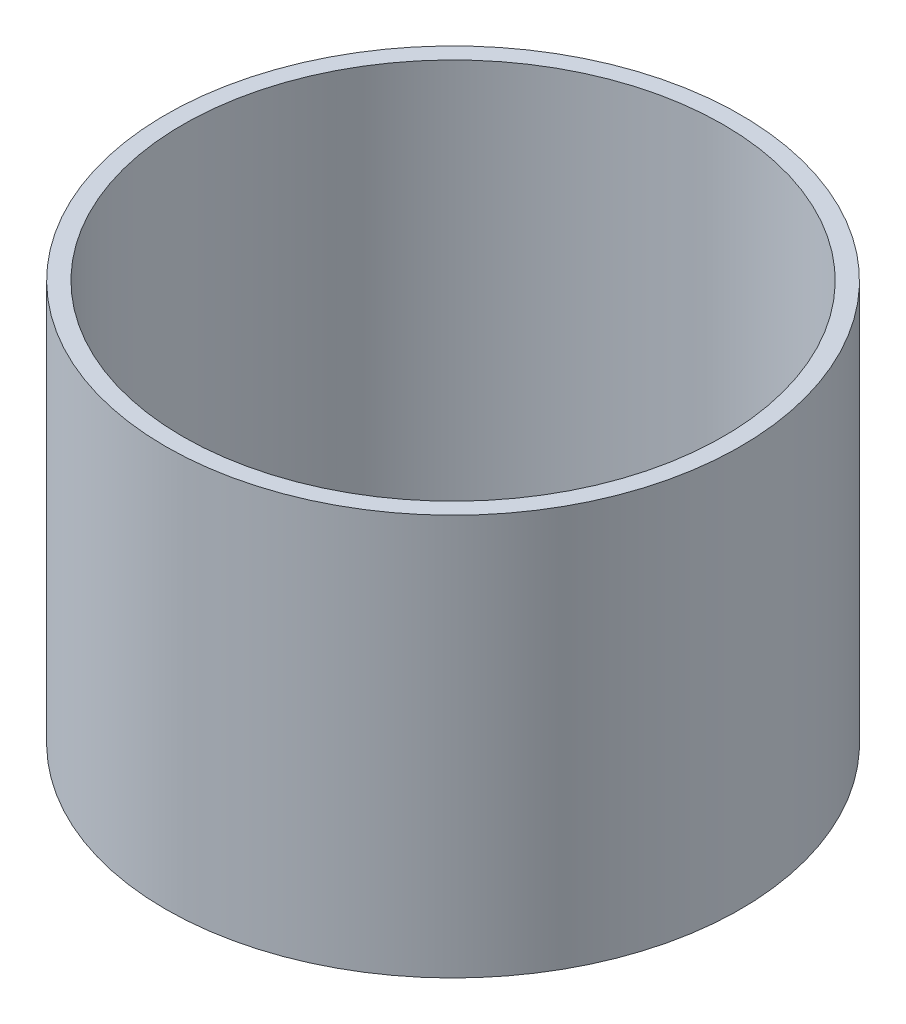
from build123d import *

# Parameters (mm, degrees)
ESQUISSE1_R        = 50.2
ESQUISSE1_R_2      = 47.2
BOSS_EXTRU_1_DEPTH = 70


with BuildPart() as part:
    # Esquisse1 → Boss.-Extru.1 (new body)
    with BuildSketch(Plane(origin=(0, 0, 0), x_dir=(1, 0, 0), z_dir=(0, 1, 0))):
        Circle(ESQUISSE1_R)
        Circle(ESQUISSE1_R_2, mode=Mode.SUBTRACT)
    extrude(amount=BOSS_EXTRU_1_DEPTH)


solid = part.part
